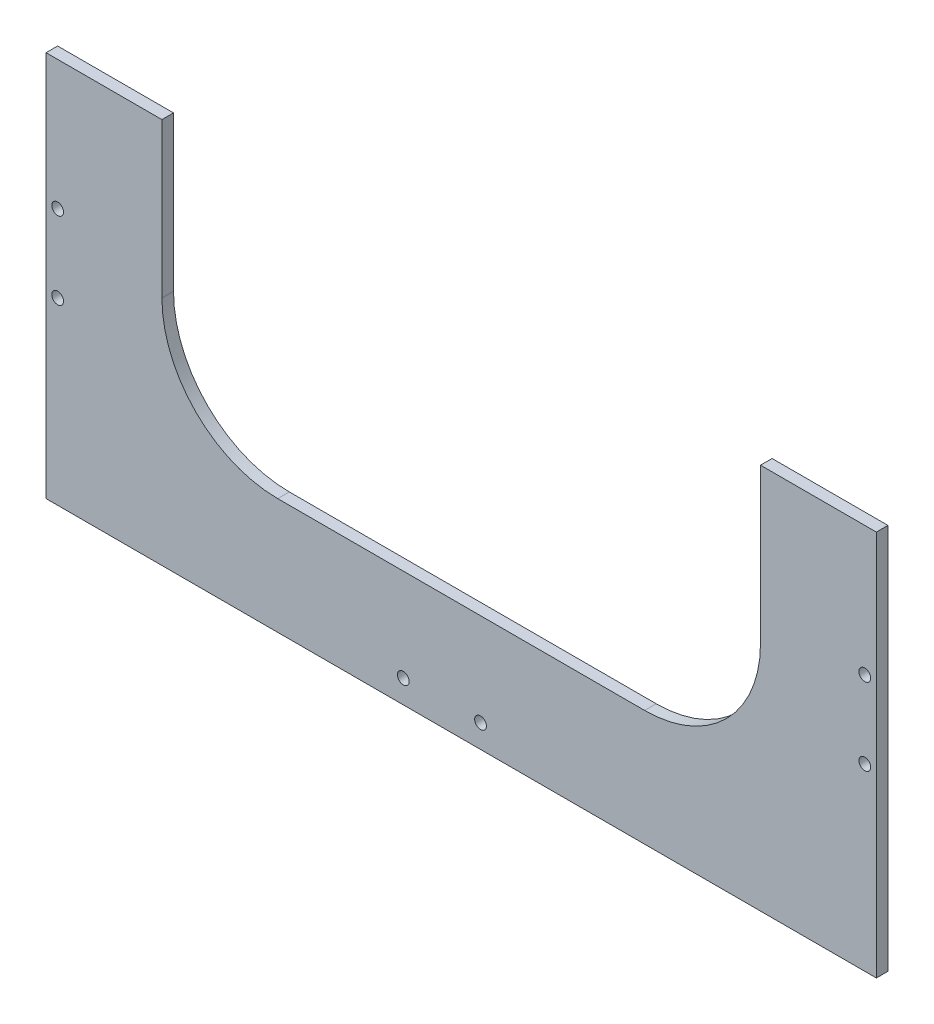
from build123d import *

# Parameters (mm, degrees)
SKETCH_1_W          = 215
SKETCH_1_H          = 100
EXTRUDE_1_DEPTH     = 1.5
SKETCH_2_W          = 155
SKETCH_2_H          = 140
CUT_EXTRUDE_1_DEPTH = 21.5
FILLET_1_R          = 30
SKETCH_3_R          = 1.525
CUT_EXTRUDE_2_DEPTH = 10
SKETCH_4_R          = 1.525
CUT_EXTRUDE_3_DEPTH = 10


with BuildPart() as part:
    # 草图1 → 凸台-拉伸1 (new body, symmetric)
    with BuildSketch(Plane.XY):
        Rectangle(SKETCH_1_W, SKETCH_1_H)
    extrude(amount=EXTRUDE_1_DEPTH, both=True)

    # 草图2 → 切除-拉伸1 (cut, symmetric)
    with BuildSketch(Plane.XY.offset(1.5)):
        with Locations((0, 50)):
            Rectangle(SKETCH_2_W, SKETCH_2_H)
    extrude(amount=CUT_EXTRUDE_1_DEPTH, both=True, mode=Mode.SUBTRACT)

    # 圆角1
    fillet_1_edges = [part.edges().sort_by_distance(p)[0] for p in [
        (77.5, -20, 0),
        (-77.5, -20, 0),
    ]]
    fillet(fillet_1_edges, radius=FILLET_1_R)

    # 草图3 → 切除-拉伸2 (cut)
    with BuildSketch(Plane(origin=(0, 0, -1.5), x_dir=(-1, 0, 0), z_dir=(0, 0, -1))):
        with Locations((-5, -44)):
            Circle(SKETCH_3_R)
        with Locations((15, -44)):
            Circle(SKETCH_3_R)
    extrude(amount=-CUT_EXTRUDE_2_DEPTH, mode=Mode.SUBTRACT)

    # 草图4 → 切除-拉伸3 (cut)
    with BuildSketch(Plane.XY.offset(1.5)):
        with Locations((-104.5, 16.5)):
            Circle(SKETCH_4_R)
        with Locations((-104.5, -3.5)):
            Circle(SKETCH_4_R)
    cut_extrude_3 = extrude(amount=-CUT_EXTRUDE_3_DEPTH, mode=Mode.SUBTRACT)

    # 镜向1: 切除-拉伸3 across plane
    add(cut_extrude_3.mirror(Plane(origin=(0, 0, 0), x_dir=(0, 0, 1), z_dir=(1, 0, 0))), mode=Mode.SUBTRACT)


solid = part.part
